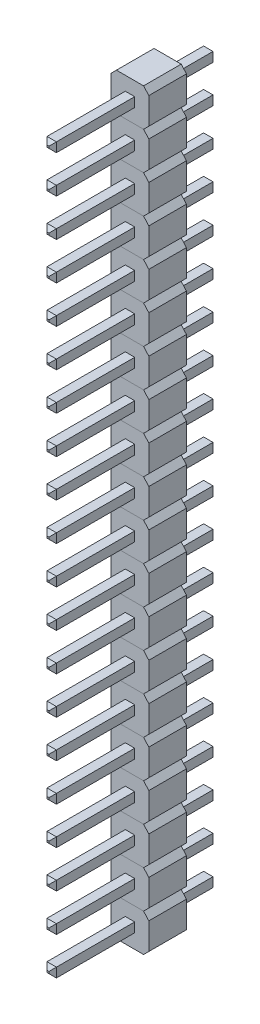
from build123d import *

# Parameters (mm, degrees)
PIN_DRAWING_W            = 0.636
PIN_DRAWING_H            = 0.636
BOSS_EXTRUDE1_DEPTH      = 2.54
SKETCH1_W                = 0.636
SKETCH1_H                = 0.636
BOSS_EXTRUDE2_DEPTH      = 5.5372
BOSS_EXTRUDE2_DEPTH_BACK = 5.5372
CHAMFER1_SIZE            = 0.25
LPATTERN2_COUNT          = 20
LPATTERN2_PITCH          = 2.54


with BuildPart() as part:
    # pin_drawing → Boss-Extrude1 (new body)
    with BuildSketch(Plane.XY):
        Polygon((-0.916946609, 1.25), (0.916946609, 1.25), (1.2705, 0.856446609), (1.2705, -0.936446609), (0.916946609, -1.29), (-0.916946609, -1.29), (-1.2705, -0.896446609), (-1.2705, 0.896446609), align=None)
        Rectangle(PIN_DRAWING_W, PIN_DRAWING_H, mode=Mode.SUBTRACT)
    extrude(amount=BOSS_EXTRUDE1_DEPTH)


with BuildPart() as body_2:
    # Sketch1 → Boss-Extrude2 (new body, two sides)
    with BuildSketch(Plane.XY.offset(2.54)) as boss_extrude2_sk:
        Rectangle(SKETCH1_W, SKETCH1_H)
    extrude(amount=BOSS_EXTRUDE2_DEPTH)
    extrude(boss_extrude2_sk.sketch, amount=-BOSS_EXTRUDE2_DEPTH_BACK)

    # Chamfer1
    chamfer1_edges = [body_2.edges().sort_by_distance(p)[0] for p in [
        (0, 0.318, -2.9972),
        (0, -0.318, 8.0772),
        (0.318, 0, 8.0772),
        (-0.318, 0, -2.9972),
        (0, 0.318, 8.0772),
        (-0.318, 0, 8.0772),
        (0, -0.318, -2.9972),
        (0.318, 0, -2.9972),
    ]]
    chamfer(chamfer1_edges, length=CHAMFER1_SIZE)


with BuildPart() as lpattern2_1:
    # LPattern2: pattern copy
    add(part.part.moved(Location(Vector(0, -1, 0) * (1 * LPATTERN2_PITCH))))


with BuildPart() as lpattern2_2:
    # LPattern2: pattern copy
    add(part.part.moved(Location(Vector(0, -1, 0) * (2 * LPATTERN2_PITCH))))


with BuildPart() as lpattern2_3:
    # LPattern2: pattern copy
    add(part.part.moved(Location(Vector(0, -1, 0) * (3 * LPATTERN2_PITCH))))


with BuildPart() as lpattern2_4:
    # LPattern2: pattern copy
    add(part.part.moved(Location(Vector(0, -1, 0) * (4 * LPATTERN2_PITCH))))


with BuildPart() as lpattern2_5:
    # LPattern2: pattern copy
    add(part.part.moved(Location(Vector(0, -1, 0) * (5 * LPATTERN2_PITCH))))


with BuildPart() as lpattern2_6:
    # LPattern2: pattern copy
    add(part.part.moved(Location(Vector(0, -1, 0) * (6 * LPATTERN2_PITCH))))


with BuildPart() as lpattern2_7:
    # LPattern2: pattern copy
    add(part.part.moved(Location(Vector(0, -1, 0) * (7 * LPATTERN2_PITCH))))


with BuildPart() as lpattern2_8:
    # LPattern2: pattern copy
    add(part.part.moved(Location(Vector(0, -1, 0) * (8 * LPATTERN2_PITCH))))


with BuildPart() as lpattern2_9:
    # LPattern2: pattern copy
    add(part.part.moved(Location(Vector(0, -1, 0) * (9 * LPATTERN2_PITCH))))


with BuildPart() as lpattern2_10:
    # LPattern2: pattern copy
    add(part.part.moved(Location(Vector(0, -1, 0) * (10 * LPATTERN2_PITCH))))


with BuildPart() as lpattern2_11:
    # LPattern2: pattern copy
    add(part.part.moved(Location(Vector(0, -1, 0) * (11 * LPATTERN2_PITCH))))


with BuildPart() as lpattern2_12:
    # LPattern2: pattern copy
    add(part.part.moved(Location(Vector(0, -1, 0) * (12 * LPATTERN2_PITCH))))


with BuildPart() as lpattern2_13:
    # LPattern2: pattern copy
    add(part.part.moved(Location(Vector(0, -1, 0) * (13 * LPATTERN2_PITCH))))


with BuildPart() as lpattern2_14:
    # LPattern2: pattern copy
    add(part.part.moved(Location(Vector(0, -1, 0) * (14 * LPATTERN2_PITCH))))


with BuildPart() as lpattern2_15:
    # LPattern2: pattern copy
    add(part.part.moved(Location(Vector(0, -1, 0) * (15 * LPATTERN2_PITCH))))


with BuildPart() as lpattern2_16:
    # LPattern2: pattern copy
    add(part.part.moved(Location(Vector(0, -1, 0) * (16 * LPATTERN2_PITCH))))


with BuildPart() as lpattern2_17:
    # LPattern2: pattern copy
    add(part.part.moved(Location(Vector(0, -1, 0) * (17 * LPATTERN2_PITCH))))


with BuildPart() as lpattern2_18:
    # LPattern2: pattern copy
    add(part.part.moved(Location(Vector(0, -1, 0) * (18 * LPATTERN2_PITCH))))


with BuildPart() as lpattern2_19:
    # LPattern2: pattern copy
    add(part.part.moved(Location(Vector(0, -1, 0) * (19 * LPATTERN2_PITCH))))


with BuildPart() as lpattern2_20:
    # LPattern2: pattern copy
    add(body_2.part.moved(Location(Vector(0, -1, 0) * (1 * LPATTERN2_PITCH))))


with BuildPart() as lpattern2_21:
    # LPattern2: pattern copy
    add(body_2.part.moved(Location(Vector(0, -1, 0) * (2 * LPATTERN2_PITCH))))


with BuildPart() as lpattern2_22:
    # LPattern2: pattern copy
    add(body_2.part.moved(Location(Vector(0, -1, 0) * (3 * LPATTERN2_PITCH))))


with BuildPart() as lpattern2_23:
    # LPattern2: pattern copy
    add(body_2.part.moved(Location(Vector(0, -1, 0) * (4 * LPATTERN2_PITCH))))


with BuildPart() as lpattern2_24:
    # LPattern2: pattern copy
    add(body_2.part.moved(Location(Vector(0, -1, 0) * (5 * LPATTERN2_PITCH))))


with BuildPart() as lpattern2_25:
    # LPattern2: pattern copy
    add(body_2.part.moved(Location(Vector(0, -1, 0) * (6 * LPATTERN2_PITCH))))


with BuildPart() as lpattern2_26:
    # LPattern2: pattern copy
    add(body_2.part.moved(Location(Vector(0, -1, 0) * (7 * LPATTERN2_PITCH))))


with BuildPart() as lpattern2_27:
    # LPattern2: pattern copy
    add(body_2.part.moved(Location(Vector(0, -1, 0) * (8 * LPATTERN2_PITCH))))


with BuildPart() as lpattern2_28:
    # LPattern2: pattern copy
    add(body_2.part.moved(Location(Vector(0, -1, 0) * (9 * LPATTERN2_PITCH))))


with BuildPart() as lpattern2_29:
    # LPattern2: pattern copy
    add(body_2.part.moved(Location(Vector(0, -1, 0) * (10 * LPATTERN2_PITCH))))


with BuildPart() as lpattern2_30:
    # LPattern2: pattern copy
    add(body_2.part.moved(Location(Vector(0, -1, 0) * (11 * LPATTERN2_PITCH))))


with BuildPart() as lpattern2_31:
    # LPattern2: pattern copy
    add(body_2.part.moved(Location(Vector(0, -1, 0) * (12 * LPATTERN2_PITCH))))


with BuildPart() as lpattern2_32:
    # LPattern2: pattern copy
    add(body_2.part.moved(Location(Vector(0, -1, 0) * (13 * LPATTERN2_PITCH))))


with BuildPart() as lpattern2_33:
    # LPattern2: pattern copy
    add(body_2.part.moved(Location(Vector(0, -1, 0) * (14 * LPATTERN2_PITCH))))


with BuildPart() as lpattern2_34:
    # LPattern2: pattern copy
    add(body_2.part.moved(Location(Vector(0, -1, 0) * (15 * LPATTERN2_PITCH))))


with BuildPart() as lpattern2_35:
    # LPattern2: pattern copy
    add(body_2.part.moved(Location(Vector(0, -1, 0) * (16 * LPATTERN2_PITCH))))


with BuildPart() as lpattern2_36:
    # LPattern2: pattern copy
    add(body_2.part.moved(Location(Vector(0, -1, 0) * (17 * LPATTERN2_PITCH))))


with BuildPart() as lpattern2_37:
    # LPattern2: pattern copy
    add(body_2.part.moved(Location(Vector(0, -1, 0) * (18 * LPATTERN2_PITCH))))


with BuildPart() as lpattern2_38:
    # LPattern2: pattern copy
    add(body_2.part.moved(Location(Vector(0, -1, 0) * (19 * LPATTERN2_PITCH))))


solid = Compound([part.part, body_2.part, lpattern2_1.part, lpattern2_2.part, lpattern2_3.part, lpattern2_4.part, lpattern2_5.part, lpattern2_6.part, lpattern2_7.part, lpattern2_8.part, lpattern2_9.part, lpattern2_10.part, lpattern2_11.part, lpattern2_12.part, lpattern2_13.part, lpattern2_14.part, lpattern2_15.part, lpattern2_16.part, lpattern2_17.part, lpattern2_18.part, lpattern2_19.part, lpattern2_20.part, lpattern2_21.part, lpattern2_22.part, lpattern2_23.part, lpattern2_24.part, lpattern2_25.part, lpattern2_26.part, lpattern2_27.part, lpattern2_28.part, lpattern2_29.part, lpattern2_30.part, lpattern2_31.part, lpattern2_32.part, lpattern2_33.part, lpattern2_34.part, lpattern2_35.part, lpattern2_36.part, lpattern2_37.part, lpattern2_38.part])
